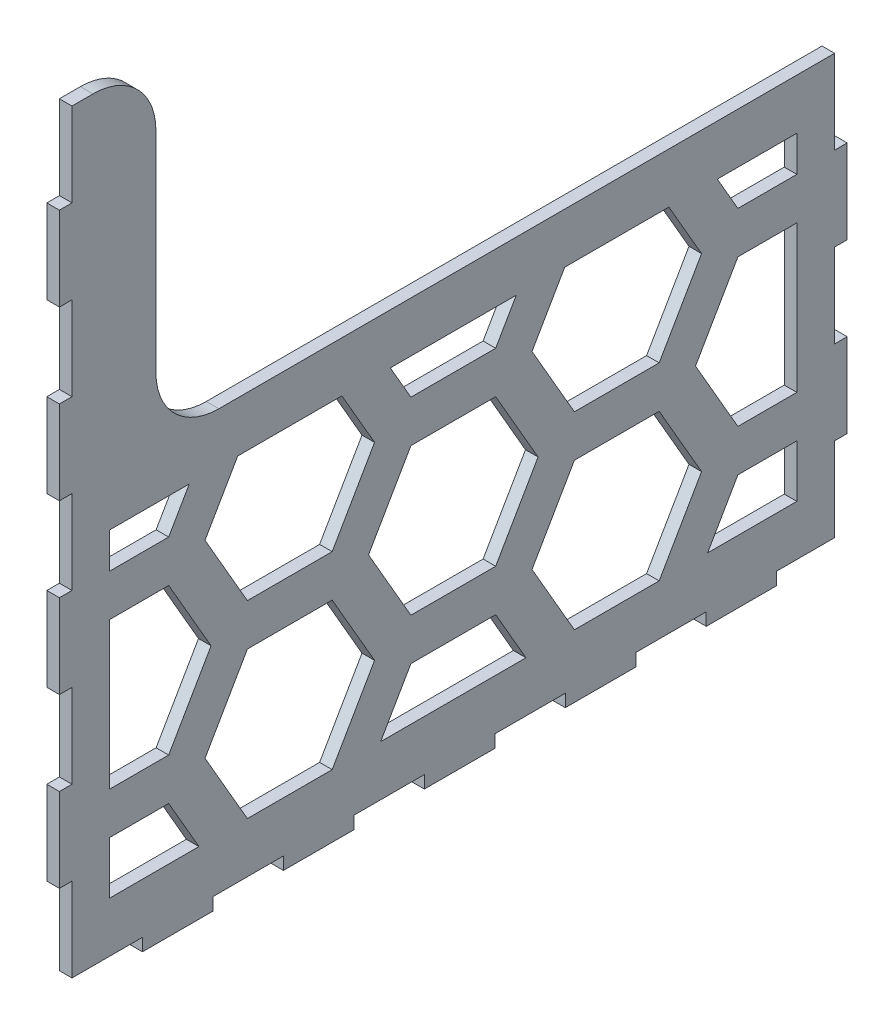
from build123d import *

# Parameters (mm, degrees)
SKETCH1_W               = 181.7773
SKETCH1_H               = 180
BOSS_EXTRUDE1_DEPTH     = 3
SKETCH2_W               = 16.797936363
SKETCH2_H               = 3
SKETCH2_W_2             = 16.797936364
SKETCH2_W_3             = 3
SKETCH2_H_2             = 20
BOSS_EXTRUDE2_DEPTH     = 3
SKETCH3_W               = 164.7773
SKETCH3_H               = 80
CUT_EXTRUDE1_DEPTH      = 1
CUT_EXTRUDE1_DEPTH_BACK = 4
FILLET1_R               = 15
CUT_EXTRUDE2_DEPTH      = 10


with BuildPart() as part:
    # Sketch1 → Boss-Extrude1 (new body)
    with BuildSketch(Plane(origin=(0, 0, 0), x_dir=(0, 0, -1), z_dir=(1, 0, 0))):
        Rectangle(SKETCH1_W, SKETCH1_H)
    extrude(amount=BOSS_EXTRUDE1_DEPTH)

    # Sketch2 → Boss-Extrude2 (add)
    with BuildSketch(Plane(origin=(3, 0, 0), x_dir=(0, 0, -1), z_dir=(1, 0, 0))):
        with Locations((-65.691745455, -91.5)):
            Rectangle(SKETCH2_W, SKETCH2_H)
        with Locations((-32.095872727, -91.5)):
            Rectangle(SKETCH2_W_2, SKETCH2_H)
        with Locations((1.5, -91.5)):
            Rectangle(SKETCH2_W_2, SKETCH2_H)
        with Locations((92.38865, -60)):
            Rectangle(SKETCH2_W_3, SKETCH2_H_2)
        with Locations((92.38865, -20)):
            Rectangle(SKETCH2_W_3, SKETCH2_H_2)
        with Locations((92.38865, 20)):
            Rectangle(SKETCH2_W_3, SKETCH2_H_2)
        with Locations((92.38865, 60)):
            Rectangle(SKETCH2_W_3, SKETCH2_H_2)
        with Locations((-92.38865, -60)):
            Rectangle(SKETCH2_W_3, SKETCH2_H_2)
        with Locations((-92.38865, -20)):
            Rectangle(SKETCH2_W_3, SKETCH2_H_2)
        with Locations((-92.38865, 20)):
            Rectangle(SKETCH2_W_3, SKETCH2_H_2)
        with Locations((-92.38865, 60)):
            Rectangle(SKETCH2_W_3, SKETCH2_H_2)
        with Locations((35.095872727, -91.5)):
            Rectangle(SKETCH2_W_2, SKETCH2_H)
        with Locations((68.691745455, -91.5)):
            Rectangle(SKETCH2_W, SKETCH2_H)
    extrude(amount=-BOSS_EXTRUDE2_DEPTH)

    # Sketch3 → Cut-Extrude1 (cut, two sides)
    with BuildSketch(Plane(origin=(3, 0, 0), x_dir=(0, 0, -1), z_dir=(1, 0, 0))) as cut_extrude1_sk:
        with Locations((11.5, 50)):
            Rectangle(SKETCH3_W, SKETCH3_H)
    extrude(amount=CUT_EXTRUDE1_DEPTH, mode=Mode.SUBTRACT)
    extrude(cut_extrude1_sk.sketch, amount=-CUT_EXTRUDE1_DEPTH_BACK, mode=Mode.SUBTRACT)

    # Fillet1
    fillet1_edges = [part.edges().sort_by_distance(p)[0] for p in [
        (1.5, 10, 70.88865),
        (1.5, 90, 70.88865),
    ]]
    fillet(fillet1_edges, radius=FILLET1_R)

    # Sketch4 → Cut-Extrude2 (cut)
    with BuildSketch(Plane.ZY):
        Polygon((-67.83865663, -65.5), (-81.88865, -65.5), (-81.88865, -78), (-60.621778265, -78), align=None)
        Polygon((-49.074772881, -43), (-59.178402592, -60.5), (-49.074772881, -78), (-28.867513459, -78), (-18.763883749, -60.5), (-28.867513459, -43), align=None)
        Polygon((-10.103629711, -65.5), (-17.320508076, -78), (17.320508076, -78), (10.103629711, -65.5), align=None)
        Polygon((28.867513459, -43), (18.763883749, -60.5), (28.867513459, -78), (49.074772881, -78), (59.178402592, -60.5), (49.074772881, -43), align=None)
        Polygon((81.88865, -78), (81.88865, -65.5), (67.83865663, -65.5), (60.621778265, -78), align=None)
        Polygon((81.88865, -55.5), (81.88865, -20.5), (67.83865663, -20.5), (57.735026919, -38), (67.83865663, -55.5), align=None)
        Polygon((51.384173958, -2), (26.558112383, -2), (18.763883749, -15.5), (28.867513459, -33), (49.074772881, -33), (59.178402592, -15.5), align=None)
        Polygon((81.88865, -10.5), (81.88865, -2), (62.931179342, -2), (67.83865663, -10.5), align=None)
        Polygon((20.207259422, -38), (10.103629711, -20.5), (-10.103629711, -20.5), (-20.207259422, -38), (-10.103629711, -55.5), (10.103629711, -55.5), align=None)
        Polygon((15.011106999, -2), (-15.011106999, -2), (-10.103629711, -10.5), (10.103629711, -10.5), align=None)
        Polygon((-26.558112383, -2), (-51.384173958, -2), (-59.178402592, -15.5), (-49.074772881, -33), (-28.867513459, -33), (-18.763883749, -15.5), align=None)
        Polygon((-67.83865663, -20.5), (-81.88865, -20.5), (-81.88865, -55.5), (-67.83865663, -55.5), (-57.735026919, -38), align=None)
        Polygon((-62.931179342, -2), (-81.88865, -2), (-81.88865, -10.5), (-67.83865663, -10.5), align=None)
    extrude(amount=-CUT_EXTRUDE2_DEPTH, mode=Mode.SUBTRACT)


solid = part.part
